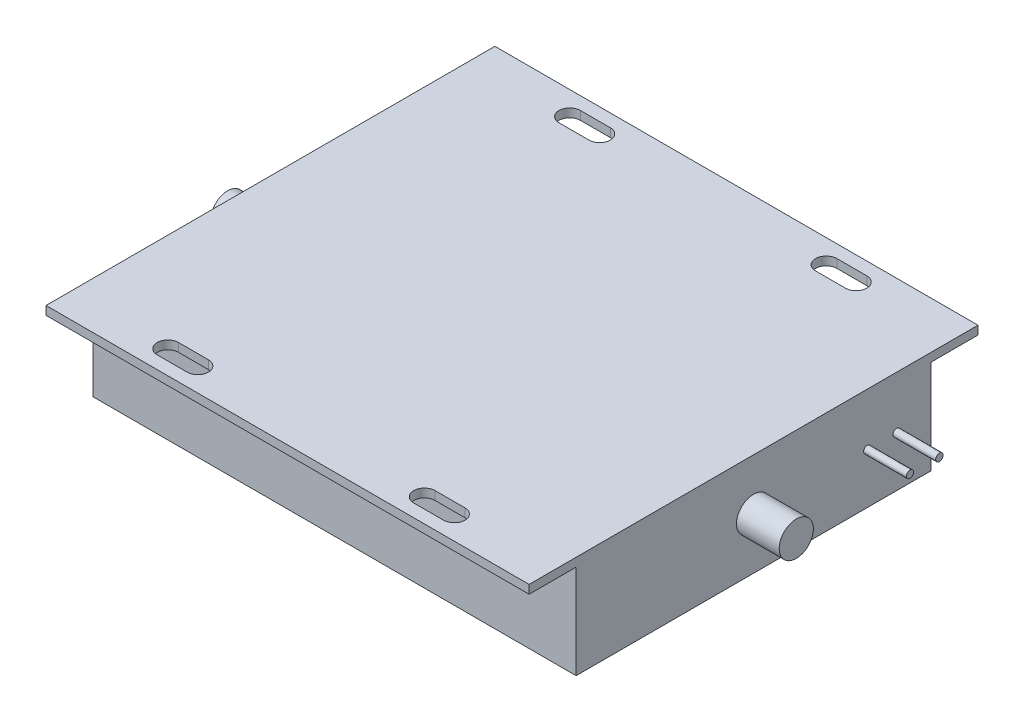
from build123d import *

# Parameters (mm, degrees)
SKETCH_1_W            = 113
SKETCH_1_H            = 83
EXTRUDE_1_DEPTH       = 24
SKETCH_21_W           = 113
SKETCH_21_H           = 2
EXTRUDE_2_DEPTH       = 52.5
CUT_EXTRUDE_20_DEPTH  = 81.774377125
MIRROR_2_COPY_1_DEPTH = 81.774377125
MIRROR_2_COPY_2_DEPTH = 81.774377125
SKETCH_27_R           = 4
EXTRUDE_4_DEPTH       = 10
SKETCH_28_R           = 0.835314329
SKETCH_28_R_2         = 0.866649433
EXTRUDE_5_DEPTH       = 10


with BuildPart() as part:
    # 草圖1 → 填料-伸長1 (new body)
    with BuildSketch(Plane(origin=(0, 31, 0), x_dir=(1, 0, 0), z_dir=(0, 1, 0))):
        Rectangle(SKETCH_1_W, SKETCH_1_H)
    extrude(amount=-EXTRUDE_1_DEPTH)

    # 草圖21 → 填料-伸長2 (add, symmetric)
    with BuildSketch(Plane(origin=(0, 0, 0), x_dir=(-1, 0, 0), z_dir=(0, 0, -1))):
        with Locations((0, 30)):
            Rectangle(SKETCH_21_W, SKETCH_21_H)
    extrude(amount=EXTRUDE_2_DEPTH, both=True)

    # 草圖22 → 除料-伸長20 (cut, through all)
    with BuildSketch(Plane(origin=(0, 31, 0), x_dir=(-1, 0, 0), z_dir=(0, 1, 0))):
        with BuildLine():
            Line((-33.5, -49.5), (-26.5, -49.5))
            ThreePointArc((-26.5, -49.5), (-24, -47), (-26.5, -44.5))
            Line((-26.5, -44.5), (-33.5, -44.5))
            ThreePointArc((-33.5, -44.5), (-36, -47), (-33.5, -49.5))
        make_face()
    cut_extrude_20 = extrude(amount=-CUT_EXTRUDE_20_DEPTH, mode=Mode.SUBTRACT)

    # 鏡射1: 除料-伸長20 across plane
    add(cut_extrude_20.mirror(Plane(origin=(0, 0, 0), x_dir=(0, 0, 1), z_dir=(1, 0, 0))), mode=Mode.SUBTRACT)

    # 鏡射2 copy 1 sketch → 鏡射2 copy 1 (cut, through all)
    with BuildSketch(Plane(origin=(0, 31, 0), x_dir=(1, 0, 0), z_dir=(0, 1, 0))):
        with BuildLine():
            Line((-33.5, -49.5), (-26.5, -49.5))
            ThreePointArc((-26.5, -49.5), (-24, -47), (-26.5, -44.5))
            Line((-26.5, -44.5), (-33.5, -44.5))
            ThreePointArc((-33.5, -44.5), (-36, -47), (-33.5, -49.5))
        make_face()
    extrude(amount=-MIRROR_2_COPY_1_DEPTH, mode=Mode.SUBTRACT)

    # 鏡射2 copy 2 sketch → 鏡射2 copy 2 (cut, through all)
    with BuildSketch(Plane(origin=(0, 31, 0), x_dir=(-1, 0, 0), z_dir=(0, 1, 0))):
        with BuildLine():
            Line((-33.5, 49.5), (-26.5, 49.5))
            ThreePointArc((-26.5, 49.5), (-24, 47), (-26.5, 44.5))
            Line((-26.5, 44.5), (-33.5, 44.5))
            ThreePointArc((-33.5, 44.5), (-36, 47), (-33.5, 49.5))
        make_face()
    extrude(amount=-MIRROR_2_COPY_2_DEPTH, mode=Mode.SUBTRACT)

    # 草圖27 → 填料-伸長4 (add)
    with BuildSketch(Plane.ZY.offset(56.5)):
        with Locations((0, 19)):
            Circle(SKETCH_27_R)
    extrude_4 = extrude(amount=EXTRUDE_4_DEPTH)

    # 鏡射3: 填料-伸長4 across plane
    add(extrude_4.mirror(Plane(origin=(0, 0, 0), x_dir=(0, 0, 1), z_dir=(1, 0, 0))))

    # 草圖28 → 填料-伸長5 (add)
    with BuildSketch(Plane(origin=(56.5, 0, 0), x_dir=(0, 0, -1), z_dir=(1, 0, 0))):
        with Locations((26.586559597, 18.769220483)):
            Circle(SKETCH_28_R)
        with Locations((33.466100625, 18.769220483)):
            Circle(SKETCH_28_R_2)
    extrude(amount=EXTRUDE_5_DEPTH)


solid = part.part
